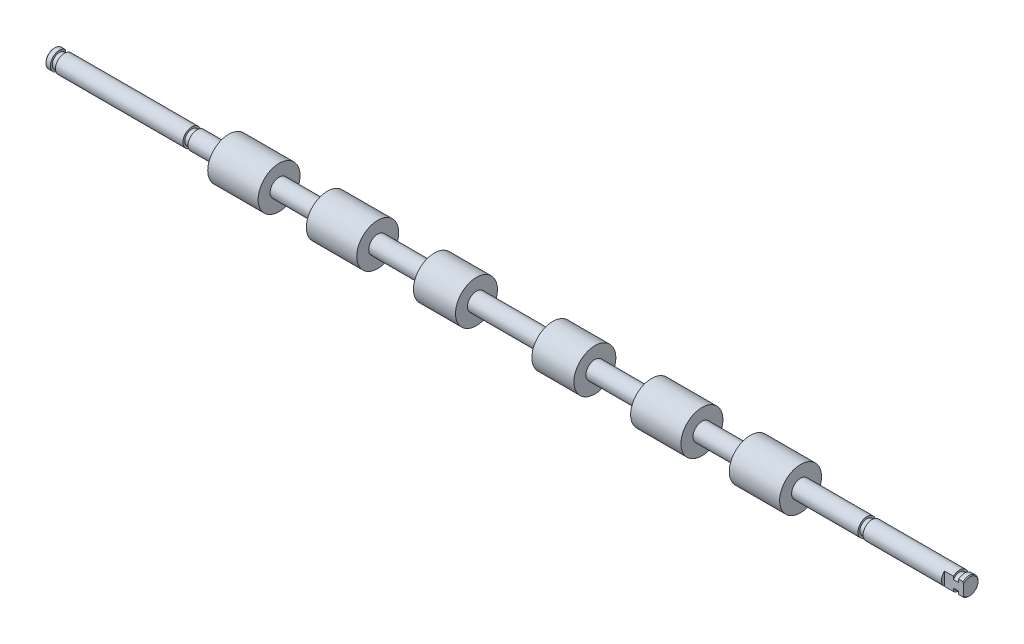
from build123d import *

# Parameters (mm, degrees)
ESQUISSE2_W                  = 16.4
ESQUISSE2_H                  = 2.788709481
ESQUISSE2_W_2                = 8.697698695
ESQUISSE2_H_2                = 2.899232898
ENL_V_MAT_EXTRU_1_DEPTH      = 7.95
ENL_V_MAT_EXTRU_1_DEPTH_BACK = 7.95
CHANFREIN1_SIZE              = 0.25


with BuildPart() as part:
    # Esquisse1 → Révolution1 (revolve)
    with BuildSketch(Plane.XY):
        Polygon((0, 0), (0, 2.975), (1.7, 2.975), (1.7, 2.35), (3.4, 2.35), (3.4, 2.975), (45.65, 2.975), (45.65, 2.35), (47.35, 2.35), (47.35, 2.975), (57.85, 2.975), (57.85, 6.95), (74.55, 6.95), (74.55, 2.975), (90.55, 2.975), (90.55, 6.95), (107.25, 6.95), (107.25, 2.975), (126.05, 2.975), (126.05, 6.95), (140, 6.95), (140, 2.975), (165.3, 2.975), (165.3, 6.95), (179.25, 6.95), (179.25, 2.975), (198.05, 2.975), (198.05, 6.95), (214.75, 6.95), (214.75, 2.975), (230.75, 2.975), (230.75, 6.95), (247.45, 6.95), (247.45, 2.975), (269.45, 2.975), (269.45, 2.35), (271.15, 2.35), (271.15, 2.975), (300.15, 2.975), (300.15, 2.35), (301.85, 2.35), (301.85, 2.975), (303.55, 2.975), (303.55, 0), align=None)
    revolve(axis=Axis((0, 0, 0), (1, 0, 0)))

    # Esquisse2 → Enlèv. mat.-Extru.1 (cut, two sides)
    with BuildSketch(Plane(origin=(0, 0, 0), x_dir=(1, 0, 0), z_dir=(0, 1, 0))) as enl_v_mat_extru_1_sk:
        with Locations((8.2, 3.399354741)):
            Rectangle(ESQUISSE2_W, ESQUISSE2_H)
        with Locations((301.498849348, -3.454616449)):
            Rectangle(ESQUISSE2_W_2, ESQUISSE2_H_2)
    extrude(amount=ENL_V_MAT_EXTRU_1_DEPTH, mode=Mode.SUBTRACT)
    extrude(enl_v_mat_extru_1_sk.sketch, amount=-ENL_V_MAT_EXTRU_1_DEPTH_BACK, mode=Mode.SUBTRACT)

    # Chanfrein1
    chanfrein1_edges = [part.edges().sort_by_distance(p)[0] for p in [
        (0, 0, 2.975),
        (303.55, 0, -2.975),
    ]]
    chamfer(chanfrein1_edges, length=CHANFREIN1_SIZE)


solid = part.part
